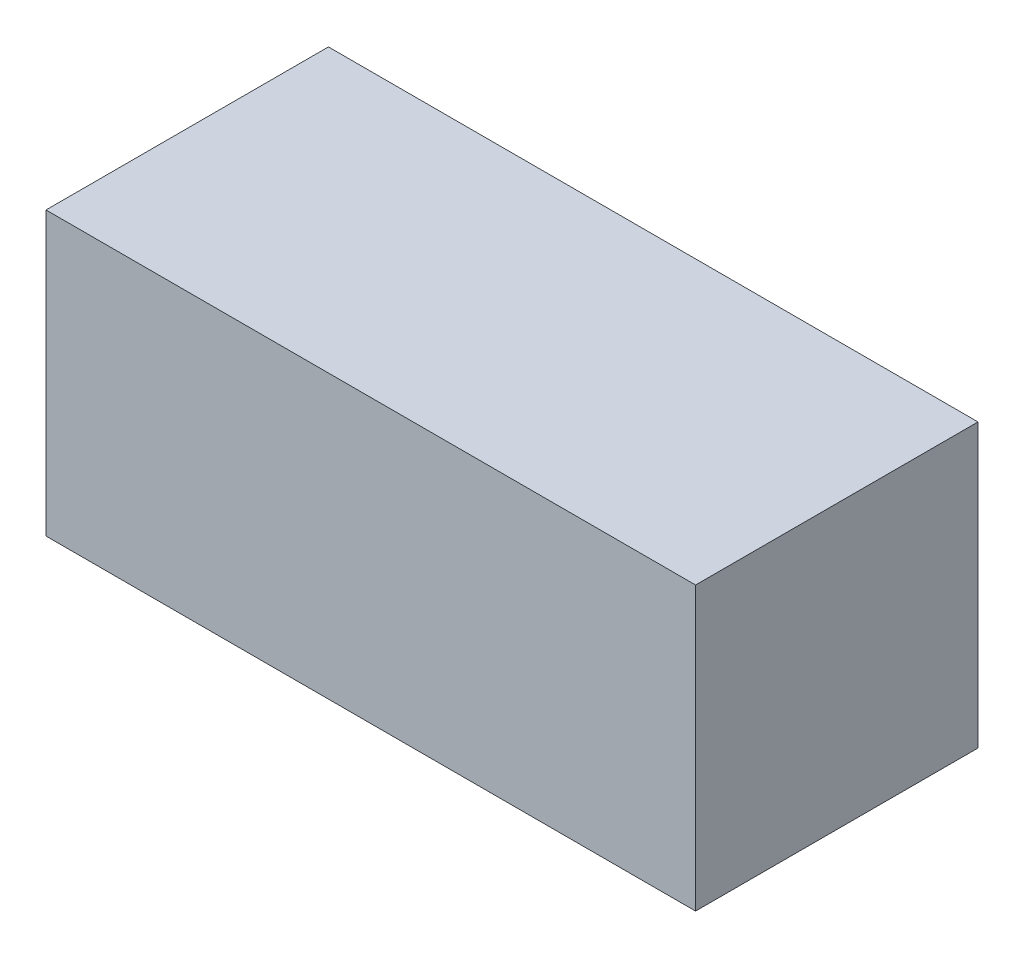
from build123d import *

# Parameters (mm, degrees)
SKETCH1_W           = 11.5
SKETCH1_H           = 5
BOSS_EXTRUDE1_DEPTH = 5


with BuildPart() as part:
    # Sketch1 → Boss-Extrude1 (new body)
    with BuildSketch(Plane.XY):
        with Locations((0, 23.8)):
            Rectangle(SKETCH1_W, SKETCH1_H)
    extrude(amount=BOSS_EXTRUDE1_DEPTH)


solid = part.part
